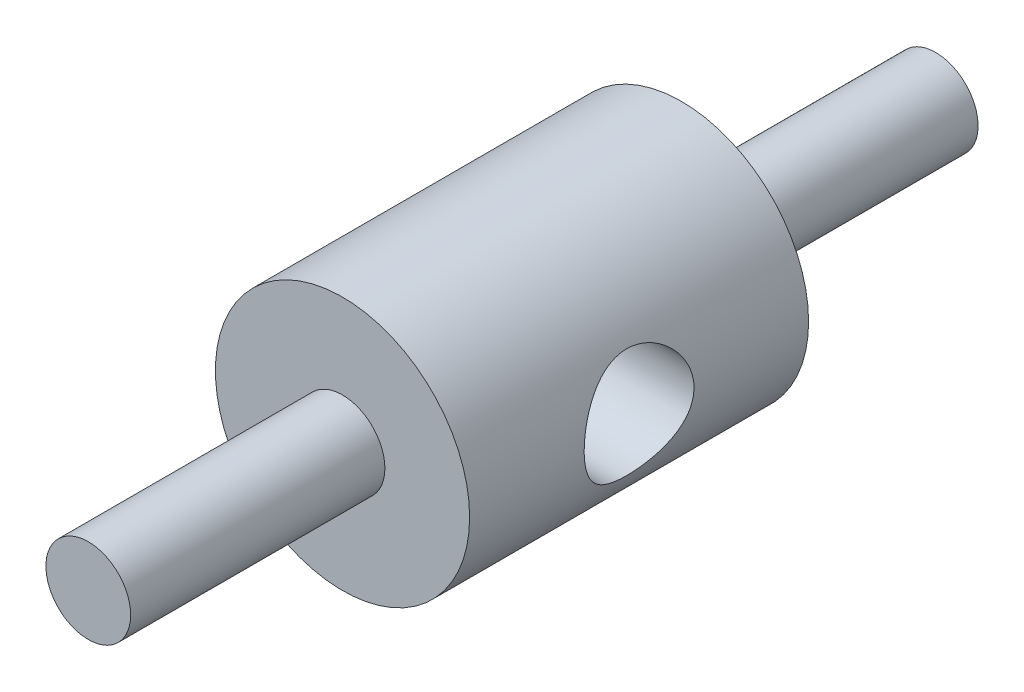
from build123d import *

# Parameters (mm, degrees)
SKETCH1_R                      = 4.7625
EXTRUDE1_DEPTH                 = 6.35
EXTRUDE1_DEPTH_BACK            = 6.35
CUT_EXTRUDE1_REACH             = 6.763
SKETCH2_R                      = 2.0574
CUT_EXTRUDE1_DIRECTION_2_REACH = 6.763
SKETCH3_R                      = 1.5875
EXTRUDE2_DEPTH                 = 9.525
EXTRUDE2_DEPTH_BACK            = 3.175
SKETCH4_R                      = 1.5875
EXTRUDE3_DEPTH                 = 9.525
EXTRUDE3_DEPTH_BACK            = 3.175


with BuildPart() as part:
    # Sketch1 → Extrude1 (new body, two sides)
    with BuildSketch(Plane.XY) as extrude1_sk:
        Circle(SKETCH1_R)
    extrude(amount=EXTRUDE1_DEPTH)
    extrude(extrude1_sk.sketch, amount=-EXTRUDE1_DEPTH_BACK)

    # Sketch2 → Cut-Extrude1 (cut, up to next)
    with BuildSketch(Plane(origin=(0, 0, 0), x_dir=(0, 0, -1), z_dir=(1, 0, 0)), mode=Mode.PRIVATE) as cut_extrude1_sk1:
        Circle(SKETCH2_R)
    cut_extrude1_tool1 = extrude(cut_extrude1_sk1.sketch, amount=-CUT_EXTRUDE1_REACH, mode=Mode.PRIVATE) & part.part
    add(cut_extrude1_tool1.solids().sort_by_distance((0, 0, 0))[0], mode=Mode.SUBTRACT)

    # Sketch2 → Cut-Extrude1 direction 2 (cut, up to next)
    with BuildSketch(Plane(origin=(0, 0, 0), x_dir=(0, 0, -1), z_dir=(1, 0, 0)), mode=Mode.PRIVATE) as cut_extrude1_direction_2_sk1:
        Circle(SKETCH2_R)
    cut_extrude1_direction_2_tool1 = extrude(cut_extrude1_direction_2_sk1.sketch, amount=CUT_EXTRUDE1_DIRECTION_2_REACH, mode=Mode.PRIVATE) & part.part
    add(cut_extrude1_direction_2_tool1.solids().sort_by_distance((0, 0, 0))[0], mode=Mode.SUBTRACT)


with BuildPart() as body_2:
    # Sketch3 → Extrude2 (new body, two sides)
    with BuildSketch(Plane.XY.offset(6.35)) as extrude2_sk:
        Circle(SKETCH3_R)
    extrude(amount=EXTRUDE2_DEPTH)
    extrude(extrude2_sk.sketch, amount=-EXTRUDE2_DEPTH_BACK)


with BuildPart() as body_3:
    # Sketch4 → Extrude3 (new body, two sides)
    with BuildSketch(Plane(origin=(0, 0, -6.35), x_dir=(-1, 0, 0), z_dir=(0, 0, -1))) as extrude3_sk:
        Circle(SKETCH4_R)
    extrude(amount=EXTRUDE3_DEPTH)
    extrude(extrude3_sk.sketch, amount=-EXTRUDE3_DEPTH_BACK)


solid = Compound([part.part, body_2.part, body_3.part])
